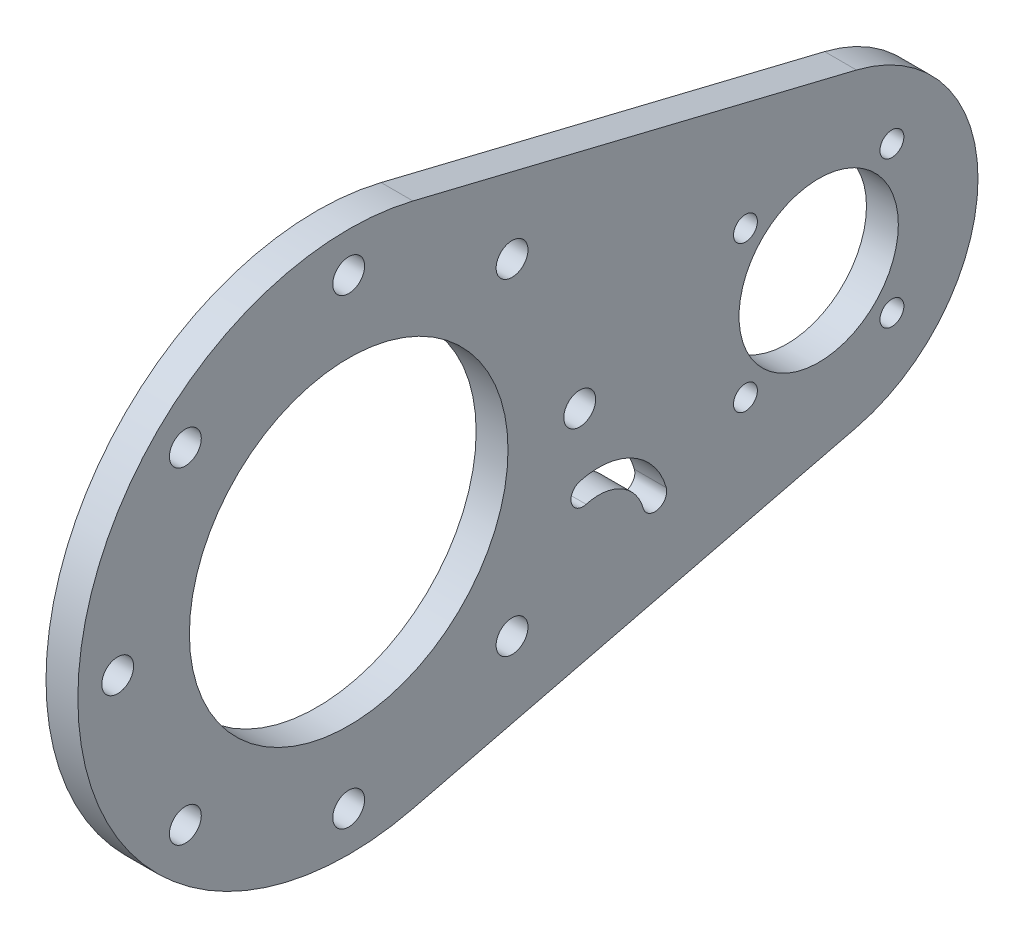
from build123d import *

# Parameters (mm, degrees)
SKETCH1_R           = 10
SKETCH1_R_2         = 20
SKETCH1_R_3         = 2
SKETCH1_R_4         = 1.5
BOSS_EXTRUDE1_DEPTH = 4
CUT_EXTRUDE1_DEPTH  = 10


with BuildPart() as part:
    # Sketch1 → Boss-Extrude1 (new body)
    with BuildSketch(Plane(origin=(0, 0, 0), x_dir=(0, 0, -1), z_dir=(1, 0, 0))):
        with BuildLine():
            Line((8.06779661, 33.028936675), (63.745762712, 19.428786279))
            ThreePointArc((63.745762712, 19.428786279), (79, 0), (63.745762712, -19.428786279))
            Line((63.745762712, -19.428786279), (8.06779661, -33.028936675))
            ThreePointArc((8.06779661, -33.028936675), (-34, 0), (8.06779661, 33.028936675))
        make_face()
        with Locations((59, 0)):
            Circle(SKETCH1_R, mode=Mode.SUBTRACT)
        Circle(SKETCH1_R_2, mode=Mode.SUBTRACT)
        with Locations((0, 29)):
            Circle(SKETCH1_R_3, mode=Mode.SUBTRACT)
        with Locations((20.506096654, 20.506096654)):
            Circle(SKETCH1_R_3, mode=Mode.SUBTRACT)
        with Locations((29, 0)):
            Circle(SKETCH1_R_3, mode=Mode.SUBTRACT)
        with Locations((20.506096654, -20.506096654)):
            Circle(SKETCH1_R_3, mode=Mode.SUBTRACT)
        with Locations((0, -29)):
            Circle(SKETCH1_R_3, mode=Mode.SUBTRACT)
        with Locations((-20.506096654, -20.506096654)):
            Circle(SKETCH1_R_3, mode=Mode.SUBTRACT)
        with Locations((-29, 0)):
            Circle(SKETCH1_R_3, mode=Mode.SUBTRACT)
        with Locations((-20.506096654, 20.506096654)):
            Circle(SKETCH1_R_3, mode=Mode.SUBTRACT)
        with Locations((49.807611845, 9.192388155)):
            Circle(SKETCH1_R_4, mode=Mode.SUBTRACT)
        with Locations((68.192388155, 9.192388155)):
            Circle(SKETCH1_R_4, mode=Mode.SUBTRACT)
        with Locations((68.192388155, -9.192388155)):
            Circle(SKETCH1_R_4, mode=Mode.SUBTRACT)
        with Locations((49.807611845, -9.192388155)):
            Circle(SKETCH1_R_4, mode=Mode.SUBTRACT)
    extrude(amount=BOSS_EXTRUDE1_DEPTH)

    # Sketch2 → Cut-Extrude1 (cut)
    with BuildSketch(Plane.ZY):
        with BuildLine():
            ThreePointArc((-28.995147078, -7.929410218), (-35.694510355, -8.730689231), (-39.865085734, -14.034444257))
            ThreePointArc((-39.865085734, -14.034444257), (-38.826287735, -15.884011427), (-36.976720565, -14.845213428))
            ThreePointArc((-36.976720565, -14.845213428), (-34.225428136, -11.346372207), (-29.805916249, -10.817775387))
            ThreePointArc((-29.805916249, -10.817775387), (-27.956349079, -9.778977388), (-28.995147078, -7.929410218))
        make_face()
    extrude(amount=-CUT_EXTRUDE1_DEPTH, mode=Mode.SUBTRACT)


solid = part.part
